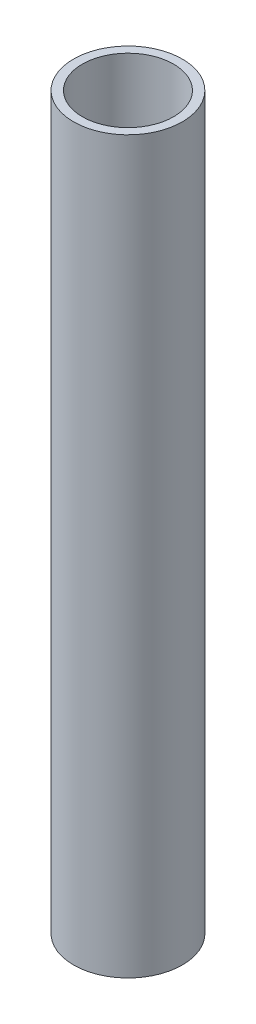
from build123d import *

# Parameters (mm, degrees)
SKETCH1_R           = 9.4615
SKETCH1_R_2         = 7.9375
BOSS_EXTRUDE1_DEPTH = 63.5


with BuildPart() as part:
    # Sketch1 → Boss-Extrude1 (new body, symmetric)
    with BuildSketch(Plane(origin=(0, 0, 0), x_dir=(1, 0, 0), z_dir=(0, 1, 0))):
        Circle(SKETCH1_R)
        Circle(SKETCH1_R_2, mode=Mode.SUBTRACT)
    extrude(amount=BOSS_EXTRUDE1_DEPTH, both=True)


solid = part.part
